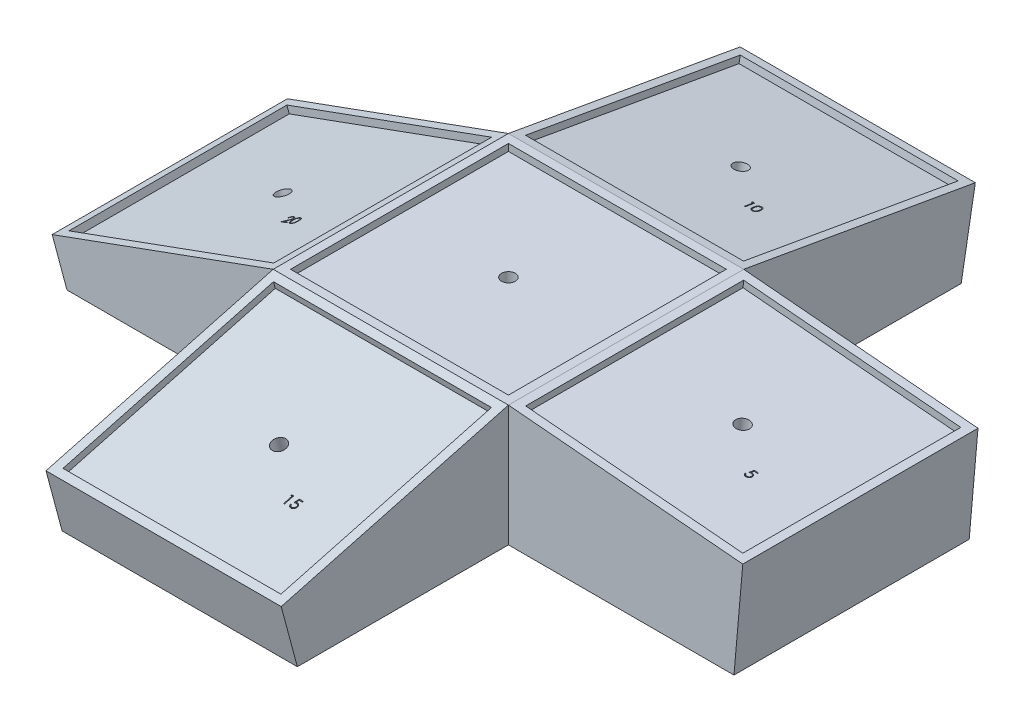
from build123d import *

# Parameters (mm, degrees)
SKETCH1_W            = 86.36
SKETCH1_H            = 86.36
SKETCH1_W_2          = 80.01
SKETCH1_H_2          = 80.01
BOSS_EXTRUDE1_DEPTH  = 2.54
SKETCH2_W            = 86.36
SKETCH2_H            = 86.36
BOSS_EXTRUDE2_DEPTH  = 8.89
SKETCH3_R            = 2.54
CUT_EXTRUDE1_DEPTH   = 8.89
SKETCH4_W            = 86.36
SKETCH4_H            = 86.36
SKETCH4_W_2          = 80.01
SKETCH4_H_2          = 80.01
BOSS_EXTRUDE3_DEPTH  = 2.54
SKETCH5_W            = 86.36
SKETCH5_H            = 86.36
BOSS_EXTRUDE4_DEPTH  = 8.89
SKETCH6_R            = 2.54
CUT_EXTRUDE2_DEPTH   = 8.89
SKETCH7_W            = 86.36
SKETCH7_H            = 86.36
SKETCH7_W_2          = 80.01
SKETCH7_H_2          = 80.01
BOSS_EXTRUDE5_DEPTH  = 2.54
SKETCH8_W            = 86.36
SKETCH8_H            = 86.36
BOSS_EXTRUDE6_DEPTH  = 8.89
SKETCH9_R            = 2.54
CUT_EXTRUDE3_DEPTH   = 8.89
SKETCH10_W           = 86.36
SKETCH10_H           = 86.36
SKETCH10_W_2         = 80.01
SKETCH10_H_2         = 80.01
BOSS_EXTRUDE7_DEPTH  = 2.54
SKETCH11_W           = 86.36
SKETCH11_H           = 86.36
BOSS_EXTRUDE8_DEPTH  = 8.89
SKETCH12_R           = 2.54
CUT_EXTRUDE4_DEPTH   = 8.89
SKETCH14_W           = 86.36
SKETCH14_H           = 86.36
SKETCH14_W_2         = 80.01
SKETCH14_H_2         = 80.01
BOSS_EXTRUDE10_DEPTH = 2.54
SKETCH15_W           = 86.36
SKETCH15_H           = 86.36
BOSS_EXTRUDE11_DEPTH = 8.89
SKETCH16_R           = 2.54
CUT_EXTRUDE5_DEPTH   = 8.89
CUT_EXTRUDE11_DEPTH  = 2.54
CUT_EXTRUDE12_DEPTH  = 2.54
CUT_EXTRUDE13_DEPTH  = 2.54
CUT_EXTRUDE14_DEPTH  = 2.54
BOSS_EXTRUDE12_REACH = 46.45
SKETCH35_W           = 81.151854731
SKETCH35_H           = 86.36
CUT_EXTRUDE15_REACH  = 91.301
SKETCH36_W           = 5.100594425
SKETCH36_H           = 88.9
SKETCH40_W           = 86.36
SKETCH40_H           = 86.36
BOSS_EXTRUDE16_DEPTH = 33.02
BOSS_EXTRUDE17_REACH = 46.45
SKETCH41_W           = 86.36
SKETCH41_H           = 83.417354358
CUT_EXTRUDE16_REACH  = 77.869
SKETCH42_W           = 86.36
SKETCH42_H           = 5.71948349
BOSS_EXTRUDE18_REACH = 46.45
SKETCH43_W           = 86.031374127
SKETCH43_H           = 86.36
CUT_EXTRUDE19_REACH  = 49.45
SKETCH44_W           = 3.21807154
SKETCH44_H           = 86.36
BOSS_EXTRUDE19_REACH = 46.45
SKETCH45_W           = 86.36
SKETCH45_H           = 85.04799755
CUT_EXTRUDE20_REACH  = 63.826
SKETCH46_W           = 86.36
SKETCH46_H           = 5.114588863


with BuildPart() as part:
    # Sketch1 → Boss-Extrude1 (new body)
    with BuildSketch(Plane(origin=(0, 0, 0), x_dir=(1, 0, 0), z_dir=(0, 1, 0))):
        with Locations((40.005, 40.005)):
            Rectangle(SKETCH1_W, SKETCH1_H)
        with Locations((40.005, 40.005)):
            Rectangle(SKETCH1_W_2, SKETCH1_H_2, mode=Mode.SUBTRACT)
    extrude(amount=BOSS_EXTRUDE1_DEPTH)

    # Sketch2 → Boss-Extrude2 (add)
    with BuildSketch(Plane.XZ):
        with Locations((40.005, -40.005)):
            Rectangle(SKETCH2_W, SKETCH2_H)
    extrude(amount=BOSS_EXTRUDE2_DEPTH)

    # Sketch3 → Cut-Extrude1 (cut)
    with BuildSketch(Plane(origin=(0, 0, 0), x_dir=(1, 0, 0), z_dir=(0, 1, 0))):
        with Locations((40.005, 40.005)):
            Circle(SKETCH3_R)
    extrude(amount=-CUT_EXTRUDE1_DEPTH, mode=Mode.SUBTRACT)



with BuildPart() as body_2:
    # Sketch4 → Boss-Extrude3 (new body)
    with BuildSketch(Plane(origin=(0.852416718, 9.743167676, 0), x_dir=(0, 0, -1), z_dir=(0.087155743, 0.996194698, 0))):
        with Locations((40.005, -125.827080374)):
            Rectangle(SKETCH4_W, SKETCH4_H)
        with Locations((40.005, -125.827080374)):
            Rectangle(SKETCH4_W_2, SKETCH4_H_2, mode=Mode.SUBTRACT)
    extrude(amount=-BOSS_EXTRUDE3_DEPTH)

    # Sketch5 → Boss-Extrude4 (add)
    with BuildSketch(Plane(origin=(0.631041132, 7.212833143, 0), x_dir=(0.996194698, -0.087155743, 0), z_dir=(-0.087155743, -0.996194698, 0))):
        with Locations((125.827080374, -40.005)):
            Rectangle(SKETCH5_W, SKETCH5_H)
    extrude(amount=BOSS_EXTRUDE4_DEPTH)

    # Sketch6 → Cut-Extrude2 (cut)
    with BuildSketch(Plane(origin=(0.631041132, 7.212833143, 0), x_dir=(0.996194698, -0.087155743, 0), z_dir=(0.087155743, 0.996194698, 0))):
        with Locations((125.827080374, 40.005)):
            Circle(SKETCH6_R)
    extrude(amount=-CUT_EXTRUDE2_DEPTH, mode=Mode.SUBTRACT)


with BuildPart() as part_1:
    add(part.part)

    add(body_2.part)  # Boss-Extrude5 merges body 2
    # Sketch7 → Boss-Extrude5 (add)
    with BuildSketch(Plane(origin=(0, 16.68888244, -2.942700252), x_dir=(-1, 0, 0), z_dir=(0, 0.984807753, -0.173648178))):
        with Locations((-40.005, -124.660166563)):
            Rectangle(SKETCH7_W, SKETCH7_H)
        with Locations((-40.005, -124.660166563)):
            Rectangle(SKETCH7_W_2, SKETCH7_H_2, mode=Mode.SUBTRACT)
    extrude(amount=-BOSS_EXTRUDE5_DEPTH)

    # Sketch8 → Boss-Extrude6 (add)
    with BuildSketch(Plane(origin=(0, 14.187470747, -2.501633881), x_dir=(1, 0, 0), z_dir=(0, -0.984807753, 0.173648178))):
        with Locations((40.005, -124.660166563)):
            Rectangle(SKETCH8_W, SKETCH8_H)
    extrude(amount=BOSS_EXTRUDE6_DEPTH)

    # Sketch9 → Cut-Extrude3 (cut)
    with BuildSketch(Plane(origin=(0, 14.187470747, -2.501633881), x_dir=(1, 0, 0), z_dir=(0, 0.984807753, -0.173648178))):
        with Locations((40.005, 124.660166563)):
            Circle(SKETCH9_R)
    extrude(amount=-CUT_EXTRUDE3_DEPTH, mode=Mode.SUBTRACT)

    # Sketch10 → Boss-Extrude7 (add)
    with BuildSketch(Plane(origin=(0, 3.163602263, 0.847684671), x_dir=(1, 0, 0), z_dir=(0, 0.965925826, 0.258819045))):
        with Locations((40.005, -45.589414124)):
            Rectangle(SKETCH10_W, SKETCH10_H)
        with Locations((40.005, -45.589414124)):
            Rectangle(SKETCH10_W_2, SKETCH10_H_2, mode=Mode.SUBTRACT)
    extrude(amount=-BOSS_EXTRUDE7_DEPTH)

    # Sketch11 → Boss-Extrude8 (add)
    with BuildSketch(Plane(origin=(0, 0.710150664, 0.190284297), x_dir=(1, 0, 0), z_dir=(0, -0.965925826, -0.258819045))):
        with Locations((40.005, 45.589414124)):
            Rectangle(SKETCH11_W, SKETCH11_H)
    extrude(amount=BOSS_EXTRUDE8_DEPTH)

    # Sketch12 → Cut-Extrude4 (cut)
    with BuildSketch(Plane(origin=(0, 0.710150664, 0.190284297), x_dir=(1, 0, 0), z_dir=(0, 0.965925826, 0.258819045))):
        with Locations((40.005, -45.589414124)):
            Circle(SKETCH12_R)
    extrude(amount=-CUT_EXTRUDE4_DEPTH, mode=Mode.SUBTRACT)

    # Sketch14 → Boss-Extrude10 (add)
    with BuildSketch(Plane(origin=(-1.187744711, 3.263301773, 0), x_dir=(0, 0, 1), z_dir=(-0.342020143, 0.939692621, 0))):
        with Locations((-40.005, -45.294792907)):
            Rectangle(SKETCH14_W, SKETCH14_H)
        with Locations((-40.005, -45.294792907)):
            Rectangle(SKETCH14_W_2, SKETCH14_H_2, mode=Mode.SUBTRACT)
    extrude(amount=-BOSS_EXTRUDE10_DEPTH)

    # Sketch15 → Boss-Extrude11 (add)
    with BuildSketch(Plane(origin=(-0.319013547, 0.876482516, 0), x_dir=(0, 0, -1), z_dir=(0.342020143, -0.939692621, 0))):
        with Locations((40.005, -45.294792907)):
            Rectangle(SKETCH15_W, SKETCH15_H)
    extrude(amount=BOSS_EXTRUDE11_DEPTH)

    # Sketch16 → Cut-Extrude5 (cut)
    with BuildSketch(Plane(origin=(-0.319013547, 0.876482516, 0), x_dir=(0, 0, 1), z_dir=(-0.342020143, 0.939692621, 0))):
        with Locations((-40.005, -45.294792907)):
            Circle(SKETCH16_R)
    extrude(amount=-CUT_EXTRUDE5_DEPTH, mode=Mode.SUBTRACT)

    # Sketch29 → Cut-Extrude11 (cut)
    with BuildSketch(Plane(origin=(0.631041132, 7.212833143, 0), x_dir=(0.996194698, -0.087155743, 0), z_dir=(0.087155743, 0.996194698, 0))):
        with BuildLine():
            Line((142.765413708, 28.9), (142.765413708, 28.541025641))
            Line((142.765413708, 28.541025641), (141.5749089, 28.541025641))
            Line((141.5749089, 28.541025641), (141.386307137, 27.620452724))
            add(Edge.make_bspline(
                [(141.386307137, 27.620452724), (141.423363011, 27.630682996), (141.495152907, 27.65050253), (141.601112768, 27.6725083), (141.701704972, 27.685773744), (141.766980342, 27.687585055), (141.798566752, 27.688461538)],
                knots=[0, 0, 0, 0, 0.000115302, 0.000223379, 0.000324431, 0.000419176, 0.000419176, 0.000419176, 0.000419176], degree=3))
            add(Edge.make_bspline(
                [(141.798566752, 27.688461538), (141.837650492, 27.687615603), (141.914498889, 27.685952282), (142.026937836, 27.669980432), (142.13427073, 27.644840518), (142.2362731, 27.609719996), (142.33313365, 27.564810263), (142.423961212, 27.508710322), (142.510119125, 27.443176991), (142.590061719, 27.367831979), (142.662586027, 27.284910363), (142.726352017, 27.195752492), (142.780514607, 27.101224829), (142.824075362, 27.000424221), (142.858859696, 26.894465067), (142.882011691, 26.782232485), (142.8974284, 26.664784365), (142.899150786, 26.584479795), (142.900029092, 26.543529647)],
                knots=[0, 0, 0, 0, 0.00011719, 0.000230425, 0.000339944, 0.000447481, 0.000553499, 0.000659556, 0.000767111, 0.000877722, 0.000988528, 0.001097091, 0.001206056, 0.001314692, 0.001425996, 0.001539995, 0.001658004, 0.001780798, 0.001780798, 0.001780798, 0.001780798], degree=3))
            add(Edge.make_bspline(
                [(142.900029092, 26.543529647), (142.899364017, 26.515007427), (142.898042854, 26.45834844), (142.891324267, 26.374204239), (142.878388551, 26.291841406), (142.861020826, 26.211249014), (142.838478408, 26.132579642), (142.811189355, 26.055608114), (142.777793327, 25.980813507), (142.741161952, 25.907488112), (142.699915474, 25.837289605), (142.654136966, 25.771640618), (142.605771475, 25.709556337), (142.55373009, 25.651702604), (142.497529095, 25.598459586), (142.437849128, 25.549511304), (142.375166409, 25.504029974), (142.308511166, 25.463861779), (142.239368683, 25.426898823), (142.166740466, 25.396575285), (142.092279766, 25.369464757), (142.01491489, 25.34785523), (141.934821078, 25.330922675), (141.851866302, 25.319422075), (141.766485632, 25.311045637), (141.70861062, 25.31052128), (141.679376047, 25.31025641)],
                knots=[0, 0, 0, 0, 8.5583e-05, 0.000170009, 0.000253005, 0.000335518, 0.000417186, 0.000498352, 0.000580291, 0.000662755, 0.000744161, 0.000824288, 0.000902692, 0.000980133, 0.001057498, 0.001134702, 0.00121156, 0.001289599, 0.001368002, 0.001446531, 0.001525481, 0.001605609, 0.001687289, 0.001770875, 0.001856759, 0.001944425, 0.001944425, 0.001944425, 0.001944425], degree=3))
            add(Edge.make_bspline(
                [(141.679376047, 25.31025641), (141.644501867, 25.310947248), (141.575891036, 25.31230639), (141.475370469, 25.326524876), (141.378655863, 25.346888792), (141.286525762, 25.377525062), (141.198154498, 25.415912357), (141.11473178, 25.464428528), (141.034126004, 25.519407632), (140.959613968, 25.584287985), (140.890457854, 25.655203667), (140.828551345, 25.732161308), (140.773417769, 25.81389075), (140.725940022, 25.900788904), (140.685442, 25.992627435), (140.653627012, 26.089750436), (140.627948657, 26.19165044), (140.617085237, 26.26180395), (140.611567554, 26.297435897)],
                knots=[0, 0, 0, 0, 0.000104552, 0.000205693, 0.000304023, 0.000400691, 0.00049644, 0.000592535, 0.000689779, 0.000788716, 0.000888377, 0.000986596, 0.001084603, 0.001183757, 0.001283279, 0.001385267, 0.001490017, 0.001598135, 0.001598135, 0.001598135, 0.001598135], degree=3))
            Line((140.611567554, 26.297435897), (140.925670118, 26.297435897))
            add(Edge.make_bspline(
                [(140.925670118, 26.297435897), (140.933398675, 26.264059445), (140.948253392, 26.19990805), (140.98085914, 26.109776709), (141.020725016, 26.029457485), (141.068129364, 25.957887902), (141.124679395, 25.895478905), (141.189208824, 25.839861843), (141.261556547, 25.789686713), (141.341949776, 25.747863946), (141.426762856, 25.712195193), (141.515530066, 25.688443498), (141.605834412, 25.671742605), (141.666912782, 25.670070844), (141.697605214, 25.669230769)],
                knots=[0, 0, 0, 0, 0.000102709, 0.000197412, 0.000286774, 0.000371169, 0.000454082, 0.000538572, 0.000626283, 0.000717552, 0.000809994, 0.00090168, 0.00099274, 0.001084718, 0.001084718, 0.001084718, 0.001084718], degree=3))
            add(Edge.make_bspline(
                [(141.697605214, 25.669230769), (141.727563658, 25.670051547), (141.786552081, 25.671667666), (141.873363467, 25.684106678), (141.957176341, 25.703264249), (142.037163698, 25.731934104), (142.114725238, 25.766778822), (142.187899008, 25.811493898), (142.258801885, 25.862953917), (142.325230019, 25.921910547), (142.386069468, 25.986880241), (142.439825589, 26.056357635), (142.484602503, 26.130474481), (142.522336612, 26.207947634), (142.55098991, 26.289626191), (142.571430892, 26.375127366), (142.58343395, 26.464662347), (142.58508513, 26.525731656), (142.585926528, 26.556850962)],
                knots=[0, 0, 0, 0, 8.9842e-05, 0.0001769, 0.000262612, 0.000347317, 0.000431396, 0.000517249, 0.000604055, 0.000693954, 0.000783242, 0.000870748, 0.000956963, 0.001042571, 0.001128832, 0.00121607, 0.001305907, 0.001399251, 0.001399251, 0.001399251, 0.001399251], degree=3))
            add(Edge.make_bspline(
                [(142.585926528, 26.556850962), (142.585268049, 26.584926713), (142.583979169, 26.639881002), (142.573448598, 26.720280209), (142.555131626, 26.796353251), (142.529707746, 26.868467485), (142.497428238, 26.936690927), (142.457981926, 27.001093987), (142.410628528, 27.060827821), (142.35653664, 27.115920374), (142.297278599, 27.166765249), (142.231834856, 27.210109336), (142.161574929, 27.246573253), (142.08734533, 27.278041252), (142.007380431, 27.300641997), (141.923263799, 27.317609882), (141.834087091, 27.327425245), (141.773116403, 27.328787134), (141.741775887, 27.329487179)],
                knots=[0, 0, 0, 0, 8.4208e-05, 0.000164824, 0.000242709, 0.000318547, 0.000393815, 0.000468731, 0.000544614, 0.00062196, 0.000700062, 0.000778428, 0.000856831, 0.000937299, 0.001019835, 0.001105635, 0.00119452, 0.001288536, 0.001288536, 0.001288536, 0.001288536], degree=3))
            add(Edge.make_bspline(
                [(141.741775887, 27.329487179), (141.714646958, 27.328906588), (141.658632603, 27.327707815), (141.572709776, 27.318881318), (141.482418053, 27.304642024), (141.388103558, 27.285055776), (141.28948305, 27.259424699), (141.186764649, 27.228710199), (141.079732382, 27.1919882), (141.007614658, 27.164255986), (140.970541913, 27.15)],
                knots=[0, 0, 0, 0, 8.1378e-05, 0.000168026, 0.000258858, 0.000355524, 0.000456875, 0.000564457, 0.000677092, 0.000796243, 0.000796243, 0.000796243, 0.000796243], degree=3))
            Line((140.970541913, 27.15), (141.329516272, 28.9))
            Line((141.329516272, 28.9), (142.765413708, 28.9))
        make_face()
    extrude(amount=-CUT_EXTRUDE11_DEPTH, mode=Mode.SUBTRACT)

    # Sketch30 → Cut-Extrude12 (cut)
    with BuildSketch(Plane(origin=(0, 14.187470747, -2.501633881), x_dir=(1, 0, 0), z_dir=(0, 0.984807753, -0.173648178))):
        Polygon((55.488505609, 113.555166563), (56.135641026, 113.555166563), (56.135641026, 110.055166563), (55.821538462, 110.055166563), (55.821538462, 113.196192204), (55.283076923, 113.196192204), align=None)
        with BuildLine():
            add(Edge.make_bspline(
                [(57.436923077, 111.803764319), (57.437251095, 111.859861707), (57.437888275, 111.968831691), (57.444976696, 112.127616334), (57.456752038, 112.276576623), (57.472889411, 112.415719689), (57.492527391, 112.545081453), (57.518742878, 112.66431621), (57.548555681, 112.773975817), (57.583108126, 112.874417865), (57.622095915, 112.966995568), (57.664530176, 113.05342077), (57.712094971, 113.133562702), (57.762071884, 113.208700492), (57.816483955, 113.277604187), (57.873782746, 113.34124685), (57.936204622, 113.3981576), (58.00162763, 113.450003903), (58.070644095, 113.495453374), (58.141286761, 113.535486113), (58.214041867, 113.56968598), (58.289108049, 113.596576416), (58.365810607, 113.618787263), (58.444417674, 113.63397621), (58.525059038, 113.643533119), (58.579490473, 113.644446787), (58.607095353, 113.644910153)],
                knots=[0, 0, 0, 0, 0.000168282, 0.000326891, 0.000476705, 0.00061646, 0.000747059, 0.00086904, 0.000982494, 0.001087814, 0.001187428, 0.001283689, 0.001376399, 0.001466822, 0.001554203, 0.001639568, 0.001723424, 0.001807301, 0.001889751, 0.001971063, 0.002050735, 0.002130583, 0.002210036, 0.002290062, 0.002370508, 0.002453288, 0.002453288, 0.002453288, 0.002453288], degree=3))
            add(Edge.make_bspline(
                [(58.607095353, 113.644910153), (58.634930831, 113.644422338), (58.69028684, 113.643452227), (58.772127215, 113.634128284), (58.852076897, 113.618657161), (58.929795036, 113.596736186), (59.005920022, 113.56954051), (59.07985643, 113.535453393), (59.152063511, 113.495774525), (59.221393799, 113.449150648), (59.288608414, 113.397168372), (59.352056377, 113.338405703), (59.411743463, 113.273455984), (59.468418768, 113.20301412), (59.520474366, 113.125729035), (59.570047798, 113.042944925), (59.614419834, 112.95321406), (59.657154509, 112.858033593), (59.694041496, 112.754769934), (59.727307741, 112.644005173), (59.75418671, 112.524430986), (59.776575982, 112.396674741), (59.793920878, 112.260267258), (59.80655352, 112.115500942), (59.813226605, 111.962280552), (59.814483306, 111.857522703), (59.815128205, 111.803764319)],
                knots=[0, 0, 0, 0, 8.3481e-05, 0.000166017, 0.000246731, 0.000327534, 0.000408041, 0.000488986, 0.000571522, 0.000654944, 0.000739373, 0.000826202, 0.000914021, 0.001003809, 0.001097153, 0.001193347, 0.001293057, 0.001397277, 0.001506176, 0.001621751, 0.001744038, 0.001873599, 0.002010742, 0.002156422, 0.002309427, 0.002470709, 0.002470709, 0.002470709, 0.002470709], degree=3))
            add(Edge.make_bspline(
                [(59.815128205, 111.803764319), (59.814476621, 111.750240412), (59.813207035, 111.64595126), (59.806628328, 111.493420284), (59.793669697, 111.349422241), (59.777459708, 111.213611779), (59.755008745, 111.08655416), (59.727403579, 110.967809711), (59.696753256, 110.85686564), (59.658918462, 110.754630828), (59.617507752, 110.659679105), (59.572452556, 110.571011957), (59.52418273, 110.487845664), (59.471593985, 110.410845917), (59.415540571, 110.33946726), (59.354822783, 110.274969637), (59.291152198, 110.215798966), (59.223739782, 110.163147338), (59.15332823, 110.117062533), (59.081369154, 110.075848683), (59.00658577, 110.042615988), (58.930672817, 110.014080947), (58.852544451, 109.992280495), (58.772298061, 109.97720664), (58.690341825, 109.966634791), (58.63494026, 109.965828311), (58.607095353, 109.965422973)],
                knots=[0, 0, 0, 0, 0.000160581, 0.000312886, 0.000457868, 0.000594226, 0.000723097, 0.000844701, 0.000959884, 0.001068125, 0.001171421, 0.001270505, 0.001366343, 0.001459687, 0.001550023, 0.00163832, 0.001725149, 0.001810562, 0.001894568, 0.001977446, 0.00205903, 0.002139777, 0.00222058, 0.002301983, 0.002384599, 0.00246808, 0.00246808, 0.00246808, 0.00246808], degree=3))
            add(Edge.make_bspline(
                [(58.607095353, 109.965422973), (58.579491239, 109.965889329), (58.525061314, 109.966808891), (58.444408888, 109.976322622), (58.366126445, 109.991618125), (58.289827691, 110.013034729), (58.215121176, 110.039249566), (58.143024889, 110.073403249), (58.072737205, 110.112737318), (58.004445649, 110.15753274), (57.939433488, 110.208854423), (57.877334883, 110.265618712), (57.819709864, 110.329242123), (57.766075768, 110.398720046), (57.71510168, 110.473413288), (57.668212307, 110.554341661), (57.624841453, 110.641184272), (57.585197962, 110.734502183), (57.550049299, 110.83565711), (57.519001591, 110.945806289), (57.494487433, 111.065921925), (57.473504478, 111.195039292), (57.456580095, 111.333713223), (57.445025769, 111.482019001), (57.437884454, 111.63986421), (57.437249384, 111.748133984), (57.436923077, 111.803764319)],
                knots=[0, 0, 0, 0, 8.278e-05, 0.000163226, 0.000243252, 0.00032184, 0.00040079, 0.000480463, 0.00056082, 0.000642298, 0.000725191, 0.000809047, 0.000894412, 0.000982346, 0.001072188, 0.001165503, 0.001262704, 0.001363236, 0.001469448, 0.001583766, 0.001706286, 0.001836995, 0.001976138, 0.002125253, 0.002283161, 0.002450041, 0.002450041, 0.002450041, 0.002450041], degree=3))
        make_face()
        with BuildLine():
            add(Edge.make_bspline(
                [(57.751025641, 111.805166563), (57.751145088, 111.758417864), (57.751376911, 111.667687819), (57.757433112, 111.535844558), (57.765683344, 111.41287423), (57.776324641, 111.298620693), (57.79212759, 111.193470681), (57.809834378, 111.096700998), (57.831382467, 111.00882376), (57.856877485, 110.92923595), (57.885916582, 110.856586881), (57.917622446, 110.788985666), (57.951683168, 110.72563373), (57.989802319, 110.667100121), (58.031317382, 110.613193957), (58.075290641, 110.562961125), (58.123363226, 110.518164144), (58.189866968, 110.464437289), (58.277663443, 110.408918155), (58.388283898, 110.360572065), (58.501952349, 110.330189609), (58.579103599, 110.326325853), (58.617612179, 110.324397332)],
                knots=[0, 0, 0, 0, 0.000140231, 0.000272162, 0.000395845, 0.00050998, 0.000616273, 0.00071473, 0.000805025, 0.000887508, 0.000965234, 0.00103957, 0.001111417, 0.001180842, 0.001248855, 0.001315406, 0.001380877, 0.0014457, 0.001571746, 0.00169106, 0.001806864, 0.001922266, 0.001922266, 0.001922266, 0.001922266], degree=3))
            add(Edge.make_bspline(
                [(58.617612179, 110.324397332), (58.656369851, 110.325995113), (58.733805174, 110.329187376), (58.846938969, 110.359986113), (58.95676924, 110.406455653), (59.04284118, 110.461403158), (59.108323723, 110.513731488), (59.155240713, 110.558346136), (59.198302762, 110.608302003), (59.239144837, 110.662201299), (59.276603912, 110.721073783), (59.31066705, 110.784636359), (59.341750398, 110.853065536), (59.359459444, 110.900835276), (59.368513622, 110.92525871)],
                knots=[0, 0, 0, 0, 0.000116044, 0.000231848, 0.000349318, 0.000472837, 0.000536674, 0.000600645, 0.000666733, 0.000734322, 0.000803367, 0.000875831, 0.000950509, 0.001028633, 0.001028633, 0.001028633, 0.001028633], degree=3))
            add(Edge.make_bspline(
                [(59.368513622, 110.92525871), (59.37906539, 110.95648845), (59.400490003, 111.019898214), (59.428101778, 111.118261866), (59.449847177, 111.22146463), (59.469410543, 111.328889747), (59.482763599, 111.441329448), (59.493511412, 111.558435832), (59.499842099, 111.680297194), (59.50062685, 111.763092185), (59.501025641, 111.805166563)],
                knots=[0, 0, 0, 0, 9.8886e-05, 0.00020078, 0.000306259, 0.000415188, 0.00052824, 0.000645799, 0.000767957, 0.000894177, 0.000894177, 0.000894177, 0.000894177], degree=3))
            add(Edge.make_bspline(
                [(59.501025641, 111.805166563), (59.500475452, 111.847234136), (59.499399164, 111.9295273), (59.495285176, 112.050045481), (59.484661602, 112.164513242), (59.472862483, 112.273423715), (59.455465262, 112.376174017), (59.436707455, 112.473624323), (59.411506243, 112.564567347), (59.384586468, 112.650426929), (59.353776072, 112.730227584), (59.319860338, 112.80434137), (59.283638579, 112.873126095), (59.244296339, 112.936393036), (59.202300656, 112.994425579), (59.156543106, 113.046060174), (59.108838734, 113.092897142), (59.042021548, 113.146359711), (58.954547258, 113.200871406), (58.845701611, 113.251037166), (58.732430966, 113.279845459), (58.655857512, 113.283907146), (58.617612179, 113.285935794)],
                knots=[0, 0, 0, 0, 0.000126219, 0.000246912, 0.000361616, 0.00047102, 0.00057545, 0.000674176, 0.000768567, 0.000858368, 0.000944043, 0.001024988, 0.001102772, 0.001177091, 0.00124833, 0.001317386, 0.001383826, 0.001448649, 0.001573728, 0.001692043, 0.001806995, 0.001921698, 0.001921698, 0.001921698, 0.001921698], degree=3))
            add(Edge.make_bspline(
                [(58.617612179, 113.285935794), (58.578901587, 113.283904347), (58.501409882, 113.279837753), (58.386961927, 113.251144499), (58.277257575, 113.201131534), (58.190014601, 113.146179161), (58.123150814, 113.09384085), (58.076068121, 113.048454396), (58.031921949, 112.998808141), (57.991254249, 112.944406226), (57.953164965, 112.885940859), (57.918183953, 112.822952094), (57.886666623, 112.75512073), (57.857582087, 112.682504295), (57.832009299, 112.60292335), (57.810915336, 112.515154357), (57.791428283, 112.418692465), (57.777633014, 112.312972957), (57.765369258, 112.198690804), (57.75748791, 112.075413485), (57.751356652, 111.943349105), (57.751138188, 111.852149946), (57.751025641, 111.805166563)],
                knots=[0, 0, 0, 0, 0.000116101, 0.000232413, 0.000351368, 0.000476447, 0.000540832, 0.000605795, 0.000672346, 0.000739935, 0.00080936, 0.000881545, 0.00095588, 0.001033607, 0.001116089, 0.001206384, 0.001304286, 0.001411174, 0.001526077, 0.001649061, 0.001781692, 0.001922624, 0.001922624, 0.001922624, 0.001922624], degree=3))
        make_face(mode=Mode.SUBTRACT)
    extrude(amount=-CUT_EXTRUDE12_DEPTH, mode=Mode.SUBTRACT)

    # Sketch31 → Cut-Extrude13 (cut)
    with BuildSketch(Plane(origin=(0, 0.710150664, 0.190284297), x_dir=(1, 0, 0), z_dir=(0, 0.965925826, 0.258819045))):
        Polygon((55.488505609, -56.694414124), (56.135641026, -56.694414124), (56.135641026, -60.194414124), (55.821538462, -60.194414124), (55.821538462, -57.053388483), (55.283076923, -57.053388483), align=None)
        with BuildLine():
            Line((59.635641026, -56.694414124), (59.635641026, -57.053388483))
            Line((59.635641026, -57.053388483), (58.445136218, -57.053388483))
            Line((58.445136218, -57.053388483), (58.256534455, -57.9739614))
            add(Edge.make_bspline(
                [(58.256534455, -57.9739614), (58.29359033, -57.963731128), (58.365380225, -57.943911594), (58.471340086, -57.921905824), (58.57193229, -57.90864038), (58.63720766, -57.906829069), (58.668794071, -57.905952585)],
                knots=[0, 0, 0, 0, 0.000115302, 0.000223379, 0.000324431, 0.000419176, 0.000419176, 0.000419176, 0.000419176], degree=3))
            add(Edge.make_bspline(
                [(58.668794071, -57.905952585), (58.70787781, -57.906798521), (58.784726208, -57.908461842), (58.897165155, -57.924433692), (59.004498048, -57.949573606), (59.106500418, -57.984694128), (59.203360969, -58.029603861), (59.29418853, -58.085703801), (59.380346443, -58.151237133), (59.460289037, -58.226582145), (59.532813345, -58.309503761), (59.596579335, -58.398661632), (59.650741925, -58.493189294), (59.69430268, -58.593989903), (59.729087014, -58.699949057), (59.752239009, -58.812181639), (59.767655718, -58.929629759), (59.769378104, -59.009934329), (59.77025641, -59.050884476)],
                knots=[0, 0, 0, 0, 0.00011719, 0.000230425, 0.000339944, 0.000447481, 0.000553499, 0.000659556, 0.000767111, 0.000877722, 0.000988528, 0.001097091, 0.001206056, 0.001314692, 0.001425996, 0.001539995, 0.001658004, 0.001780798, 0.001780798, 0.001780798, 0.001780798], degree=3))
            add(Edge.make_bspline(
                [(59.77025641, -59.050884476), (59.769591335, -59.079406697), (59.768270172, -59.136065684), (59.761551585, -59.220209885), (59.748615869, -59.302572718), (59.731248145, -59.38316511), (59.708705727, -59.461834482), (59.681416673, -59.53880601), (59.648020645, -59.613600617), (59.61138927, -59.686926012), (59.570142792, -59.757124519), (59.524364285, -59.822773506), (59.475998793, -59.884857787), (59.423957408, -59.94271152), (59.367756413, -59.995954538), (59.308076446, -60.04490282), (59.245393727, -60.09038415), (59.178738485, -60.130552345), (59.109596002, -60.167515301), (59.036967784, -60.197838838), (58.962507084, -60.224949367), (58.885142208, -60.246558894), (58.805048396, -60.263491449), (58.72209362, -60.274992049), (58.63671295, -60.283368487), (58.578837938, -60.283892844), (58.549603365, -60.284157714)],
                knots=[0, 0, 0, 0, 8.5583e-05, 0.000170009, 0.000253005, 0.000335518, 0.000417186, 0.000498352, 0.000580291, 0.000662755, 0.000744161, 0.000824288, 0.000902692, 0.000980133, 0.001057498, 0.001134702, 0.00121156, 0.001289599, 0.001368002, 0.001446531, 0.001525481, 0.001605609, 0.001687289, 0.001770875, 0.001856759, 0.001944425, 0.001944425, 0.001944425, 0.001944425], degree=3))
            add(Edge.make_bspline(
                [(58.549603365, -60.284157714), (58.514729185, -60.283466876), (58.446118354, -60.282107734), (58.345597787, -60.267889248), (58.248883181, -60.247525332), (58.15675308, -60.216889062), (58.068381816, -60.178501767), (57.984959099, -60.129985596), (57.904353323, -60.075006492), (57.829841286, -60.010126139), (57.760685172, -59.939210457), (57.698778663, -59.862252816), (57.643645087, -59.780523374), (57.59616734, -59.69362522), (57.555669318, -59.601786689), (57.52385433, -59.504663688), (57.498175975, -59.402763684), (57.487312555, -59.332610174), (57.481794872, -59.296978226)],
                knots=[0, 0, 0, 0, 0.000104552, 0.000205693, 0.000304023, 0.000400691, 0.00049644, 0.000592535, 0.000689779, 0.000788716, 0.000888377, 0.000986596, 0.001084603, 0.001183757, 0.001283279, 0.001385267, 0.001490017, 0.001598135, 0.001598135, 0.001598135, 0.001598135], degree=3))
            Line((57.481794872, -59.296978226), (57.795897436, -59.296978226))
            add(Edge.make_bspline(
                [(57.795897436, -59.296978226), (57.803625993, -59.330354679), (57.81848071, -59.394506074), (57.851086458, -59.484637415), (57.890952334, -59.564956639), (57.938356682, -59.636526222), (57.994906713, -59.698935219), (58.059436142, -59.754552281), (58.131783865, -59.804727411), (58.212177095, -59.846550178), (58.296990174, -59.882218931), (58.385757384, -59.905970626), (58.47606173, -59.922671519), (58.537140101, -59.92434328), (58.567832532, -59.925183355)],
                knots=[0, 0, 0, 0, 0.000102709, 0.000197412, 0.000286774, 0.000371169, 0.000454082, 0.000538572, 0.000626283, 0.000717552, 0.000809994, 0.00090168, 0.00099274, 0.001084718, 0.001084718, 0.001084718, 0.001084718], degree=3))
            add(Edge.make_bspline(
                [(58.567832532, -59.925183355), (58.597790976, -59.924362577), (58.656779399, -59.922746458), (58.743590785, -59.910307446), (58.82740366, -59.891149875), (58.907391016, -59.86248002), (58.984952556, -59.827635302), (59.058126326, -59.782920226), (59.129029203, -59.731460207), (59.195457337, -59.672503577), (59.256296786, -59.607533883), (59.310052907, -59.538056489), (59.354829821, -59.463939643), (59.39256393, -59.38646649), (59.421217228, -59.304787933), (59.44165821, -59.219286757), (59.453661269, -59.129751777), (59.455312449, -59.068682467), (59.456153846, -59.037563162)],
                knots=[0, 0, 0, 0, 8.9842e-05, 0.0001769, 0.000262612, 0.000347317, 0.000431396, 0.000517249, 0.000604055, 0.000693954, 0.000783242, 0.000870748, 0.000956963, 0.001042571, 0.001128832, 0.00121607, 0.001305907, 0.001399251, 0.001399251, 0.001399251, 0.001399251], degree=3))
            add(Edge.make_bspline(
                [(59.456153846, -59.037563162), (59.455495367, -59.009487411), (59.454206487, -58.954533122), (59.443675917, -58.874133915), (59.425358944, -58.798060873), (59.399935064, -58.725946639), (59.367655557, -58.657723197), (59.328209244, -58.593320136), (59.280855846, -58.533586303), (59.226763958, -58.47849375), (59.167505917, -58.427648875), (59.102062174, -58.384304788), (59.031802247, -58.347840871), (58.957572648, -58.316372872), (58.877607749, -58.293772127), (58.793491117, -58.276804241), (58.704314409, -58.266988879), (58.643343721, -58.26562699), (58.612003205, -58.264926944)],
                knots=[0, 0, 0, 0, 8.4208e-05, 0.000164824, 0.000242709, 0.000318547, 0.000393815, 0.000468731, 0.000544614, 0.00062196, 0.000700062, 0.000778428, 0.000856831, 0.000937299, 0.001019835, 0.001105635, 0.00119452, 0.001288536, 0.001288536, 0.001288536, 0.001288536], degree=3))
            add(Edge.make_bspline(
                [(58.612003205, -58.264926944), (58.584874276, -58.265507536), (58.528859921, -58.266706309), (58.442937094, -58.275532806), (58.352645371, -58.2897721), (58.258330876, -58.309358348), (58.159710368, -58.334989425), (58.056991967, -58.365703925), (57.9499597, -58.402425924), (57.877841976, -58.430158138), (57.840769231, -58.444414124)],
                knots=[0, 0, 0, 0, 8.1378e-05, 0.000168026, 0.000258858, 0.000355524, 0.000456875, 0.000564457, 0.000677092, 0.000796243, 0.000796243, 0.000796243, 0.000796243], degree=3))
            Line((57.840769231, -58.444414124), (58.19974359, -56.694414124))
            Line((58.19974359, -56.694414124), (59.635641026, -56.694414124))
        make_face()
    extrude(amount=-CUT_EXTRUDE13_DEPTH, mode=Mode.SUBTRACT)

    # Sketch32 → Cut-Extrude14 (cut)
    with BuildSketch(Plane(origin=(-0.319013547, 0.876482516, 0), x_dir=(0.939692621, 0.342020143, 0), z_dir=(-0.342020143, 0.939692621, 0))):
        with BuildLine():
            Line((-30.106459574, 27.823076923), (-30.420562138, 27.823076923))
            add(Edge.make_bspline(
                [(-30.420562138, 27.823076923), (-30.418514985, 27.864747811), (-30.414494431, 27.946588325), (-30.395666141, 28.065912232), (-30.368725264, 28.179967031), (-30.33063381, 28.287836945), (-30.283327532, 28.390475752), (-30.226597505, 28.487475767), (-30.159403655, 28.578466956), (-30.08319692, 28.662605799), (-30.000428281, 28.73979337), (-29.911122342, 28.806448613), (-29.817277315, 28.862766284), (-29.719177916, 28.909847526), (-29.615717352, 28.945187372), (-29.507834494, 28.971409012), (-29.395055358, 28.987185357), (-29.318215336, 28.988881143), (-29.279135856, 28.98974359)],
                knots=[0, 0, 0, 0, 0.000125083, 0.00024566, 0.000361805, 0.000476223, 0.000588214, 0.000700404, 0.000812728, 0.00092691, 0.001040529, 0.001151727, 0.001260545, 0.001368429, 0.001477521, 0.001587884, 0.001701119, 0.00181831, 0.00181831, 0.00181831, 0.00181831], degree=3))
            add(Edge.make_bspline(
                [(-29.279135856, 28.98974359), (-29.240757782, 28.988845133), (-29.165346237, 28.987079698), (-29.055284222, 28.971918669), (-28.950506928, 28.948173078), (-28.851219161, 28.914857661), (-28.758213097, 28.870073234), (-28.670790052, 28.816275695), (-28.587909242, 28.754055864), (-28.513302458, 28.68080205), (-28.444794379, 28.602599666), (-28.385692124, 28.519111762), (-28.33507896, 28.432882477), (-28.29289128, 28.343254275), (-28.261835141, 28.249383247), (-28.238256933, 28.152636044), (-28.22492952, 28.052011233), (-28.222884096, 27.983904677), (-28.221844189, 27.949278846)],
                knots=[0, 0, 0, 0, 0.000115089, 0.000226145, 0.000332614, 0.000437044, 0.000539592, 0.000641561, 0.000744629, 0.00084975, 0.000954621, 0.001056175, 0.001156101, 0.001254284, 0.001352726, 0.001452208, 0.001552655, 0.001656537, 0.001656537, 0.001656537, 0.001656537], degree=3))
            add(Edge.make_bspline(
                [(-28.221844189, 27.949278846), (-28.223537452, 27.900531012), (-28.226894263, 27.803890798), (-28.25560864, 27.661875935), (-28.300455151, 27.524282516), (-28.354452508, 27.413545214), (-28.408924952, 27.32431172), (-28.458012459, 27.250843015), (-28.51547727, 27.171737547), (-28.582155768, 27.08726021), (-28.656668641, 26.996749304), (-28.739690804, 26.900259509), (-28.831814286, 26.798787739), (-28.896472787, 26.729482138), (-28.929977202, 26.693569712)],
                knots=[0, 0, 0, 0, 0.000146118, 0.000289672, 0.0004329, 0.00057934, 0.000657978, 0.000746456, 0.000844345, 0.000951219, 0.001069268, 0.00119604, 0.001333047, 0.001480391, 0.001480391, 0.001480391, 0.001480391], degree=3))
            Line((-28.929977202, 26.693569712), (-29.805678324, 25.758974359))
            Line((-29.805678324, 25.758974359), (-28.176972394, 25.758974359))
            Line((-28.176972394, 25.758974359), (-28.176972394, 25.4))
            Line((-28.176972394, 25.4), (-30.555177522, 25.4))
            Line((-30.555177522, 25.4), (-29.197805727, 26.848517628))
            add(Edge.make_bspline(
                [(-29.197805727, 26.848517628), (-29.164757841, 26.883015935), (-29.101279614, 26.949280121), (-29.011497037, 27.046023081), (-28.930858048, 27.135772622), (-28.858840656, 27.218359171), (-28.79700715, 27.294990738), (-28.742134918, 27.363185442), (-28.698169327, 27.425939892), (-28.650453932, 27.498680506), (-28.60423995, 27.587492823), (-28.564527594, 27.696026513), (-28.540312746, 27.807753765), (-28.53740791, 27.883255802), (-28.535946753, 27.921233974)],
                knots=[0, 0, 0, 0, 0.000143319, 0.000275286, 0.00039593, 0.000505287, 0.000603949, 0.000691331, 0.000767782, 0.00083371, 0.000952247, 0.001067137, 0.001179618, 0.001293462, 0.001293462, 0.001293462, 0.001293462], degree=3))
            add(Edge.make_bspline(
                [(-28.535946753, 27.921233974), (-28.536582495, 27.945115373), (-28.537835421, 27.992181023), (-28.548893119, 28.061186782), (-28.565603625, 28.127751596), (-28.589548883, 28.192080215), (-28.621155623, 28.253525867), (-28.659629003, 28.312163347), (-28.704019066, 28.368852313), (-28.755370336, 28.422005611), (-28.811781856, 28.470686816), (-28.871376105, 28.513810902), (-28.934426209, 28.549850012), (-29.000666332, 28.579393509), (-29.069911801, 28.602568891), (-29.142296546, 28.61862747), (-29.217620562, 28.628709954), (-29.269054058, 28.630074126), (-29.295261657, 28.630769231)],
                knots=[0, 0, 0, 0, 7.16e-05, 0.00014111, 0.00020913, 0.00027724, 0.000346538, 0.000415963, 0.000487357, 0.000562233, 0.000637292, 0.000710646, 0.000782564, 0.000854749, 0.000927915, 0.001001225, 0.001076884, 0.001155488, 0.001155488, 0.001155488, 0.001155488], degree=3))
            add(Edge.make_bspline(
                [(-29.295261657, 28.630769231), (-29.32263249, 28.630054199), (-29.376384286, 28.628649993), (-29.455303319, 28.618827329), (-29.530589096, 28.601881489), (-29.602430999, 28.578704814), (-29.670950585, 28.549246266), (-29.735814629, 28.512554521), (-29.796877518, 28.468771028), (-29.854254042, 28.419130471), (-29.907118021, 28.36386287), (-29.953564897, 28.302252907), (-29.994148911, 28.235425492), (-30.029558144, 28.163560941), (-30.058313834, 28.086007161), (-30.080286985, 28.003039456), (-30.097673832, 27.915018075), (-30.103482352, 27.85423299), (-30.106459574, 27.823076923)],
                knots=[0, 0, 0, 0, 8.2106e-05, 0.000161243, 0.000238127, 0.000313291, 0.000387401, 0.000461495, 0.000536397, 0.000612445, 0.000688819, 0.000765383, 0.000843422, 0.000923066, 0.001005373, 0.001091093, 0.001180334, 0.001274175, 0.001274175, 0.001274175, 0.001274175], degree=3))
        make_face()
        with BuildLine():
            add(Edge.make_bspline(
                [(-27.86286983, 27.148597756), (-27.862541812, 27.204695144), (-27.861904632, 27.313665128), (-27.854816211, 27.47244977), (-27.843040869, 27.621410059), (-27.826903496, 27.760553125), (-27.807265516, 27.88991489), (-27.781050029, 28.009149647), (-27.751237226, 28.118809254), (-27.716684781, 28.219251302), (-27.677696991, 28.311829005), (-27.635262731, 28.398254207), (-27.587697936, 28.478396139), (-27.537721023, 28.553533929), (-27.483308952, 28.622437624), (-27.426010161, 28.686080287), (-27.363588285, 28.742991037), (-27.298165277, 28.794837339), (-27.229148812, 28.840286811), (-27.158506146, 28.88031955), (-27.08575104, 28.914519417), (-27.010684857, 28.941409853), (-26.9339823, 28.9636207), (-26.855375233, 28.978809647), (-26.774733869, 28.988366556), (-26.720302434, 28.989280224), (-26.692697554, 28.98974359)],
                knots=[0, 0, 0, 0, 0.000168282, 0.000326891, 0.000476705, 0.00061646, 0.000747059, 0.00086904, 0.000982494, 0.001087814, 0.001187428, 0.001283689, 0.001376399, 0.001466822, 0.001554203, 0.001639568, 0.001723424, 0.001807301, 0.001889751, 0.001971063, 0.002050735, 0.002130583, 0.002210036, 0.002290062, 0.002370508, 0.002453288, 0.002453288, 0.002453288, 0.002453288], degree=3))
            add(Edge.make_bspline(
                [(-26.692697554, 28.98974359), (-26.664862076, 28.989255775), (-26.609506067, 28.988285664), (-26.527665692, 28.978961721), (-26.44771601, 28.963490598), (-26.369997871, 28.941569623), (-26.293872885, 28.914373947), (-26.219936477, 28.88028683), (-26.147729396, 28.840607962), (-26.078399108, 28.793984085), (-26.011184493, 28.742001809), (-25.94773653, 28.68323914), (-25.888049444, 28.618289421), (-25.831374138, 28.547847557), (-25.779318541, 28.470562472), (-25.729745109, 28.387778362), (-25.685373073, 28.298047497), (-25.642638398, 28.20286703), (-25.605751411, 28.099603371), (-25.572485166, 27.98883861), (-25.545606197, 27.869264423), (-25.523216925, 27.741508178), (-25.505872029, 27.605100695), (-25.493239387, 27.460334379), (-25.486566302, 27.307113989), (-25.485309601, 27.20235614), (-25.484664702, 27.148597756)],
                knots=[0, 0, 0, 0, 8.3481e-05, 0.000166017, 0.000246731, 0.000327534, 0.000408041, 0.000488986, 0.000571522, 0.000654944, 0.000739373, 0.000826202, 0.000914021, 0.001003809, 0.001097153, 0.001193347, 0.001293057, 0.001397277, 0.001506176, 0.001621751, 0.001744038, 0.001873599, 0.002010742, 0.002156422, 0.002309427, 0.002470709, 0.002470709, 0.002470709, 0.002470709], degree=3))
            add(Edge.make_bspline(
                [(-25.484664702, 27.148597756), (-25.485316286, 27.095073848), (-25.486585872, 26.990784697), (-25.493164579, 26.838253721), (-25.50612321, 26.694255678), (-25.522333199, 26.558445216), (-25.544784162, 26.431387597), (-25.572389328, 26.312643148), (-25.603039651, 26.201699077), (-25.640874445, 26.099464265), (-25.682285155, 26.004512542), (-25.727340351, 25.915845394), (-25.775610177, 25.832679101), (-25.828198922, 25.755679354), (-25.884252335, 25.684300697), (-25.944970124, 25.619803074), (-26.008640709, 25.560632402), (-26.076053125, 25.507980775), (-26.146464676, 25.46189597), (-26.218423753, 25.42068212), (-26.293207137, 25.387449425), (-26.369120089, 25.358914384), (-26.447248456, 25.337113932), (-26.527494846, 25.322040077), (-26.609451082, 25.311468228), (-26.664852647, 25.310661748), (-26.692697554, 25.31025641)],
                knots=[0, 0, 0, 0, 0.000160581, 0.000312886, 0.000457868, 0.000594226, 0.000723097, 0.000844701, 0.000959884, 0.001068125, 0.001171421, 0.001270505, 0.001366343, 0.001459687, 0.001550023, 0.00163832, 0.001725149, 0.001810562, 0.001894568, 0.001977446, 0.00205903, 0.002139777, 0.00222058, 0.002301983, 0.002384599, 0.00246808, 0.00246808, 0.00246808, 0.00246808], degree=3))
            add(Edge.make_bspline(
                [(-26.692697554, 25.31025641), (-26.720301668, 25.310722766), (-26.774731593, 25.311642328), (-26.855384019, 25.321156059), (-26.933666462, 25.336451562), (-27.009965216, 25.357868166), (-27.084671731, 25.384083003), (-27.156768018, 25.418236686), (-27.227055701, 25.457570755), (-27.295347257, 25.502366177), (-27.360359419, 25.55368786), (-27.422458024, 25.610452149), (-27.480083043, 25.67407556), (-27.533717139, 25.743553483), (-27.584691227, 25.818246725), (-27.6315806, 25.899175098), (-27.674951454, 25.986017709), (-27.714594945, 26.07933562), (-27.749743608, 26.180490547), (-27.780791316, 26.290639726), (-27.805305474, 26.410755362), (-27.826288429, 26.539872729), (-27.843212812, 26.678546659), (-27.854767138, 26.826852438), (-27.861908453, 26.984697647), (-27.862543523, 27.092967421), (-27.86286983, 27.148597756)],
                knots=[0, 0, 0, 0, 8.278e-05, 0.000163226, 0.000243252, 0.00032184, 0.00040079, 0.000480463, 0.00056082, 0.000642298, 0.000725191, 0.000809047, 0.000894412, 0.000982346, 0.001072188, 0.001165503, 0.001262704, 0.001363236, 0.001469448, 0.001583766, 0.001706286, 0.001836995, 0.001976138, 0.002125253, 0.002283161, 0.002450041, 0.002450041, 0.002450041, 0.002450041], degree=3))
        make_face()
        with BuildLine():
            add(Edge.make_bspline(
                [(-27.548767266, 27.15), (-27.548647819, 27.103251301), (-27.548415996, 27.012521256), (-27.542359795, 26.880677995), (-27.534109563, 26.757707667), (-27.523468266, 26.64345413), (-27.507665317, 26.538304118), (-27.489958529, 26.441534435), (-27.46841044, 26.353657197), (-27.442915422, 26.274069387), (-27.413876325, 26.201420318), (-27.382170461, 26.133819103), (-27.348109738, 26.070467167), (-27.309990588, 26.011933558), (-27.268475525, 25.958027394), (-27.224502266, 25.907794562), (-27.176429681, 25.862997581), (-27.109925939, 25.809270726), (-27.022129464, 25.753751592), (-26.911509009, 25.705405502), (-26.797840558, 25.675023046), (-26.720689308, 25.67115929), (-26.682180727, 25.669230769)],
                knots=[0, 0, 0, 0, 0.000140231, 0.000272162, 0.000395845, 0.00050998, 0.000616273, 0.00071473, 0.000805025, 0.000887508, 0.000965234, 0.00103957, 0.001111417, 0.001180842, 0.001248855, 0.001315406, 0.001380877, 0.0014457, 0.001571746, 0.00169106, 0.001806864, 0.001922266, 0.001922266, 0.001922266, 0.001922266], degree=3))
            add(Edge.make_bspline(
                [(-26.682180727, 25.669230769), (-26.643423056, 25.67082855), (-26.565987733, 25.674020813), (-26.452853937, 25.70481955), (-26.343023667, 25.75128909), (-26.256951727, 25.806236595), (-26.191469184, 25.858564925), (-26.144552194, 25.903179573), (-26.101490145, 25.95313544), (-26.06064807, 26.007034736), (-26.023188995, 26.06590722), (-25.989125857, 26.129469796), (-25.958042509, 26.197898973), (-25.940333463, 26.245668713), (-25.931279285, 26.270092147)],
                knots=[0, 0, 0, 0, 0.000116044, 0.000231848, 0.000349318, 0.000472837, 0.000536674, 0.000600645, 0.000666733, 0.000734322, 0.000803367, 0.000875831, 0.000950509, 0.001028633, 0.001028633, 0.001028633, 0.001028633], degree=3))
            add(Edge.make_bspline(
                [(-25.931279285, 26.270092147), (-25.920727517, 26.301321887), (-25.899302904, 26.364731651), (-25.871691129, 26.463095303), (-25.84994573, 26.566298067), (-25.830382364, 26.673723184), (-25.817029308, 26.786162885), (-25.806281495, 26.903269269), (-25.799950808, 27.025130631), (-25.799166057, 27.107925622), (-25.798767266, 27.15)],
                knots=[0, 0, 0, 0, 9.8886e-05, 0.00020078, 0.000306259, 0.000415188, 0.00052824, 0.000645799, 0.000767957, 0.000894177, 0.000894177, 0.000894177, 0.000894177], degree=3))
            add(Edge.make_bspline(
                [(-25.798767266, 27.15), (-25.799317455, 27.192067573), (-25.800393743, 27.274360737), (-25.804507731, 27.394878918), (-25.815131305, 27.509346679), (-25.826930424, 27.618257152), (-25.844327645, 27.721007454), (-25.863085452, 27.818457759), (-25.888286664, 27.909400784), (-25.915206439, 27.995260366), (-25.946016835, 28.075061021), (-25.979932569, 28.149174807), (-26.016154328, 28.217959532), (-26.055496568, 28.281226473), (-26.097492251, 28.339259016), (-26.1432498, 28.390893611), (-26.190954173, 28.437730579), (-26.257771359, 28.491193148), (-26.345245649, 28.545704843), (-26.454091296, 28.595870603), (-26.567361941, 28.624678896), (-26.643935395, 28.628740583), (-26.682180727, 28.630769231)],
                knots=[0, 0, 0, 0, 0.000126219, 0.000246912, 0.000361616, 0.00047102, 0.00057545, 0.000674176, 0.000768567, 0.000858368, 0.000944043, 0.001024988, 0.001102772, 0.001177091, 0.00124833, 0.001317386, 0.001383826, 0.001448649, 0.001573728, 0.001692043, 0.001806995, 0.001921698, 0.001921698, 0.001921698, 0.001921698], degree=3))
            add(Edge.make_bspline(
                [(-26.682180727, 28.630769231), (-26.72089132, 28.628737784), (-26.798383025, 28.62467119), (-26.91283098, 28.595977936), (-27.022535332, 28.54596497), (-27.109778306, 28.491012598), (-27.176642093, 28.438674287), (-27.223724786, 28.393287833), (-27.267870958, 28.343641578), (-27.308538658, 28.289239663), (-27.346627942, 28.230774296), (-27.381608954, 28.167785531), (-27.413126284, 28.099954167), (-27.44221082, 28.027337732), (-27.467783608, 27.947756787), (-27.488877571, 27.859987794), (-27.508364624, 27.763525902), (-27.522159893, 27.657806394), (-27.534423649, 27.54352424), (-27.542304997, 27.420246922), (-27.548436255, 27.288182542), (-27.548654719, 27.196983383), (-27.548767266, 27.15)],
                knots=[0, 0, 0, 0, 0.000116101, 0.000232413, 0.000351368, 0.000476447, 0.000540832, 0.000605795, 0.000672346, 0.000739935, 0.00080936, 0.000881545, 0.00095588, 0.001033607, 0.001116089, 0.001206384, 0.001304286, 0.001411174, 0.001526077, 0.001649061, 0.001781692, 0.001922624, 0.001922624, 0.001922624, 0.001922624], degree=3))
        make_face(mode=Mode.SUBTRACT)
    extrude(amount=-CUT_EXTRUDE14_DEPTH, mode=Mode.SUBTRACT)

    # Boss-Extrude12: up to this face of the body (flat: up to its plane)
    boss_extrude12_end = Plane(part_1.part.faces().sort_by_distance((-41.342474261, -23.515376488, 1.967852196))[0])
    # Sketch35 → Boss-Extrude12 (add, up to the picked face)
    with BuildSketch(Plane(origin=(0, -41.91, 0), x_dir=(1, 0, 0), z_dir=(0, 1, 0)), mode=Mode.PRIVATE) as boss_extrude12_sk1:
        with Locations((-43.750927366, 40.005)):
            Rectangle(SKETCH35_W, SKETCH35_H)
    boss_extrude12_tool1 = split(extrude(boss_extrude12_sk1.sketch, amount=BOSS_EXTRUDE12_REACH, mode=Mode.PRIVATE), bisect_by=boss_extrude12_end, keep=Keep.BOTH, mode=Mode.PRIVATE)
    add(boss_extrude12_tool1.solids().sort_by_distance((-43.750927, -41.91, -40.005))[0])

    # Cut-Extrude15: up to this face of the body (flat: up to its plane)
    cut_extrude15_end = Plane(part_1.part.faces().sort_by_distance((-43.750927366, -41.91, -40.005))[0])
    # Sketch36 → Cut-Extrude15 (cut, up to the picked face)
    with BuildSketch(Plane(origin=(2.721545527, -7.477384882, 0), x_dir=(0.939692621, 0.342020143, 0), z_dir=(-0.342020143, 0.939692621, 0)), mode=Mode.PRIVATE) as cut_extrude15_sk1:
        with Locations((-91.02509012, 41.275)):
            Rectangle(SKETCH36_W, SKETCH36_H)
    cut_extrude15_tool1 = split(extrude(cut_extrude15_sk1.sketch, amount=-CUT_EXTRUDE15_REACH, mode=Mode.PRIVATE), bisect_by=cut_extrude15_end, keep=Keep.BOTH, mode=Mode.PRIVATE)
    add(cut_extrude15_tool1.solids().sort_by_distance((-82.81406, -38.609799, -41.275))[0], mode=Mode.SUBTRACT)

    # Sketch40 → Boss-Extrude16 (add)
    with BuildSketch(Plane(origin=(0, -41.91, 0), x_dir=(1, 0, 0), z_dir=(0, 1, 0))):
        with Locations((40.005, 40.005)):
            Rectangle(SKETCH40_W, SKETCH40_H)
    extrude(amount=BOSS_EXTRUDE16_DEPTH)

    # Boss-Extrude17: up to this face of the body (flat: up to its plane)
    boss_extrude17_end = Plane(part_1.part.faces().sort_by_distance((81.985145985, -20.072675836, 43.404526336))[0])
    # Sketch41 → Boss-Extrude17 (add, up to the picked face)
    with BuildSketch(Plane(origin=(0, -41.91, 0), x_dir=(1, 0, 0), z_dir=(0, 1, 0)), mode=Mode.PRIVATE) as boss_extrude17_sk1:
        with Locations((40.005, -44.883677179)):
            Rectangle(SKETCH41_W, SKETCH41_H)
    boss_extrude17_tool1 = split(extrude(boss_extrude17_sk1.sketch, amount=BOSS_EXTRUDE17_REACH, mode=Mode.PRIVATE), bisect_by=boss_extrude17_end, keep=Keep.BOTH, mode=Mode.PRIVATE)
    add(boss_extrude17_tool1.solids().sort_by_distance((40.005, -41.91, 44.883677))[0])

    # Cut-Extrude16: up to this face of the body (flat: up to its plane)
    cut_extrude16_end = Plane(part_1.part.faces().sort_by_distance((15.00792212, -41.91, -11.1612027))[0])
    # Sketch42 → Cut-Extrude16 (cut, up to the picked face)
    with BuildSketch(Plane(origin=(0, -7.876929932, -2.110617014), x_dir=(1, 0, 0), z_dir=(0, 0.965925826, 0.258819045)), mode=Mode.PRIVATE) as cut_extrude16_sk1:
        with Locations((40.005, -91.629155869)):
            Rectangle(SKETCH42_W, SKETCH42_H)
    cut_extrude16_tool1 = split(extrude(cut_extrude16_sk1.sketch, amount=-CUT_EXTRUDE16_REACH, mode=Mode.PRIVATE), bisect_by=cut_extrude16_end, keep=Keep.BOTH, mode=Mode.PRIVATE)
    add(cut_extrude16_tool1.solids().sort_by_distance((40.005, -31.592301, 86.396351))[0], mode=Mode.SUBTRACT)

    # Boss-Extrude18: up to this face of the body (flat: up to its plane)
    boss_extrude18_end = Plane(part_1.part.faces().sort_by_distance((125.702591994, -12.653468043, -81.970735614))[0])
    # Sketch43 → Boss-Extrude18 (add, up to the picked face)
    with BuildSketch(Plane(origin=(0, -41.91, 0), x_dir=(1, 0, 0), z_dir=(0, 1, 0)), mode=Mode.PRIVATE) as boss_extrude18_sk1:
        with Locations((126.200687064, 40.005)):
            Rectangle(SKETCH43_W, SKETCH43_H)
    boss_extrude18_tool1 = split(extrude(boss_extrude18_sk1.sketch, amount=BOSS_EXTRUDE18_REACH, mode=Mode.PRIVATE), bisect_by=boss_extrude18_end, keep=Keep.BOTH, mode=Mode.PRIVATE)
    add(boss_extrude18_tool1.solids().sort_by_distance((126.200687, -41.91, -40.005))[0])

    # Cut-Extrude19: up to this face of the body (flat: up to its plane)
    cut_extrude19_end = Plane(part_1.part.faces().sort_by_distance((43.932132291, -41.91, -20.505972932))[0])
    # Sketch44 → Cut-Extrude19 (cut, up to the picked face)
    with BuildSketch(Plane(origin=(-0.143773421, -1.643337723, 0), x_dir=(0.996194698, -0.087155743, 0), z_dir=(0.087155743, 0.996194698, 0)), mode=Mode.PRIVATE) as cut_extrude19_sk1:
        with Locations((170.616116144, 40.005)):
            Rectangle(SKETCH44_W, SKETCH44_H)
    cut_extrude19_tool1 = split(extrude(cut_extrude19_sk1.sketch, amount=-CUT_EXTRUDE19_REACH, mode=Mode.PRIVATE), bisect_by=cut_extrude19_end, keep=Keep.BOTH, mode=Mode.PRIVATE)
    add(cut_extrude19_tool1.solids().sort_by_distance((169.823097, -16.513512, -40.005))[0], mode=Mode.SUBTRACT)

    # Boss-Extrude19: up to this face of the body (flat: up to its plane)
    boss_extrude19_end = Plane(part_1.part.faces().sort_by_distance((81.977852196, -16.389467707, -124.71659944))[0])
    # Sketch45 → Boss-Extrude19 (add, up to the picked face)
    with BuildSketch(Plane(origin=(0, -41.91, 0), x_dir=(1, 0, 0), z_dir=(0, 1, 0)), mode=Mode.PRIVATE) as boss_extrude19_sk1:
        with Locations((40.005, 125.708998775)):
            Rectangle(SKETCH45_W, SKETCH45_H)
    boss_extrude19_tool1 = split(extrude(boss_extrude19_sk1.sketch, amount=BOSS_EXTRUDE19_REACH, mode=Mode.PRIVATE), bisect_by=boss_extrude19_end, keep=Keep.BOTH, mode=Mode.PRIVATE)
    add(boss_extrude19_tool1.solids().sort_by_distance((40.005, -41.91, -125.708999))[0])

    # Cut-Extrude20: up to this face of the body (flat: up to its plane)
    cut_extrude20_end = Plane(part_1.part.faces().sort_by_distance((42.131841286, -41.91, -42.311777182))[0])
    # Sketch46 → Cut-Extrude20 (cut, up to the picked face)
    with BuildSketch(Plane(origin=(0, 5.432529823, -0.957901581), x_dir=(1, 0, 0), z_dir=(0, 0.984807753, -0.173648178)), mode=Mode.PRIVATE) as cut_extrude20_sk1:
        with Locations((40.005, 170.397460995)):
            Rectangle(SKETCH46_W, SKETCH46_H)
    cut_extrude20_tool1 = split(extrude(cut_extrude20_sk1.sketch, amount=-CUT_EXTRUDE20_REACH, mode=Mode.PRIVATE), bisect_by=cut_extrude20_end, keep=Keep.BOTH, mode=Mode.PRIVATE)
    add(cut_extrude20_tool1.solids().sort_by_distance((40.005, -24.156679, -168.766642))[0], mode=Mode.SUBTRACT)


solid = part_1.part
